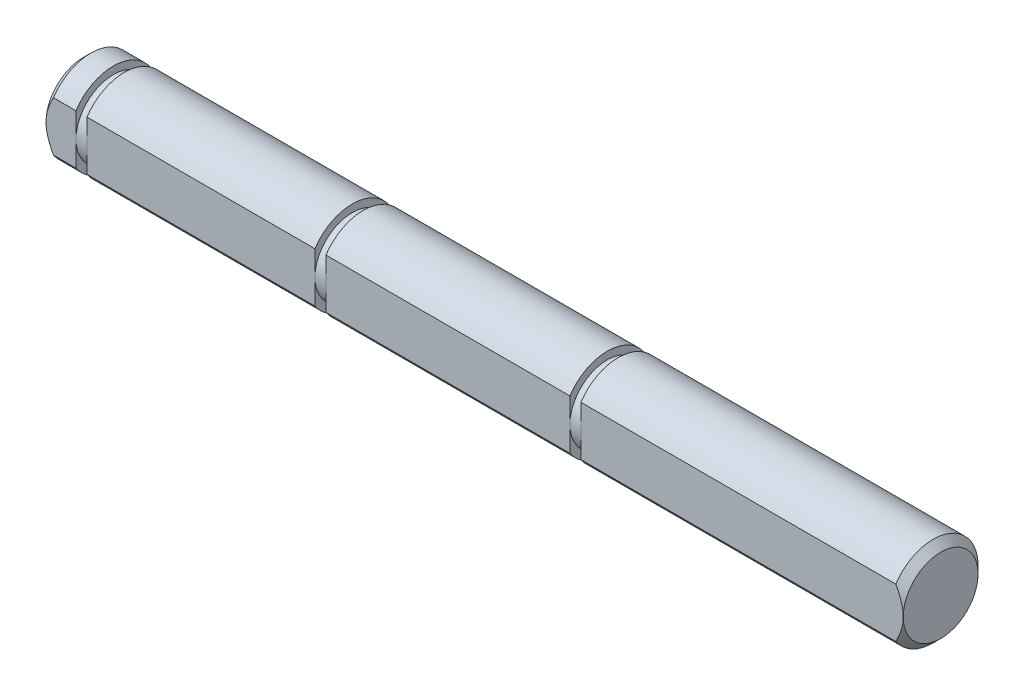
from build123d import *

# Parameters (mm, degrees)
CHAMFER1_SIZE           = 0.5
CUT_EXTRUDE1_DEPTH      = 40.538087663
CUT_EXTRUDE1_DEPTH_BACK = 40.538087663
SKETCH2_W               = 2
SKETCH2_H               = 6


with BuildPart() as part:
    # Sketch1 → Revolve1 (revolve)
    with BuildSketch(Plane.XY):
        Polygon((-17.9666, 0), (39.3098, 0), (39.3098, 3), (37.3098, 3), (36.5732, 3), (17.7732, 3), (17.7732, 2.5), (17.0366, 2.5), (17.0366, 3), (0.7366, 3), (0.7366, 2.5), (0, 2.5), (0, 3), (-15.23, 3), (-15.23, 2.5), (-15.9666, 2.5), (-15.9666, 3), (-17.9666, 3), align=None)
    revolve(axis=Axis((-17.9666, 0, 0), (-1, 0, 0)))

    # Chamfer1
    chamfer1_edges = [part.edges().sort_by_distance(p)[0] for p in [
        (39.3098, -3, 0),
        (-17.9666, -3, 0),
    ]]
    chamfer(chamfer1_edges, length=CHAMFER1_SIZE)

    # Sketch2 → Cut-Extrude1 (cut, two sides: drawn at the far end of the back side and taken through both)
    with BuildSketch(Plane(origin=(0, 0, 0), x_dir=(0, 0, -1), z_dir=(1, 0, 0)).offset(-CUT_EXTRUDE1_DEPTH_BACK)):
        with Locations((-3.5, 0)):
            Rectangle(SKETCH2_W, SKETCH2_H)
    extrude(amount=CUT_EXTRUDE1_DEPTH + CUT_EXTRUDE1_DEPTH_BACK, mode=Mode.SUBTRACT)


solid = part.part
